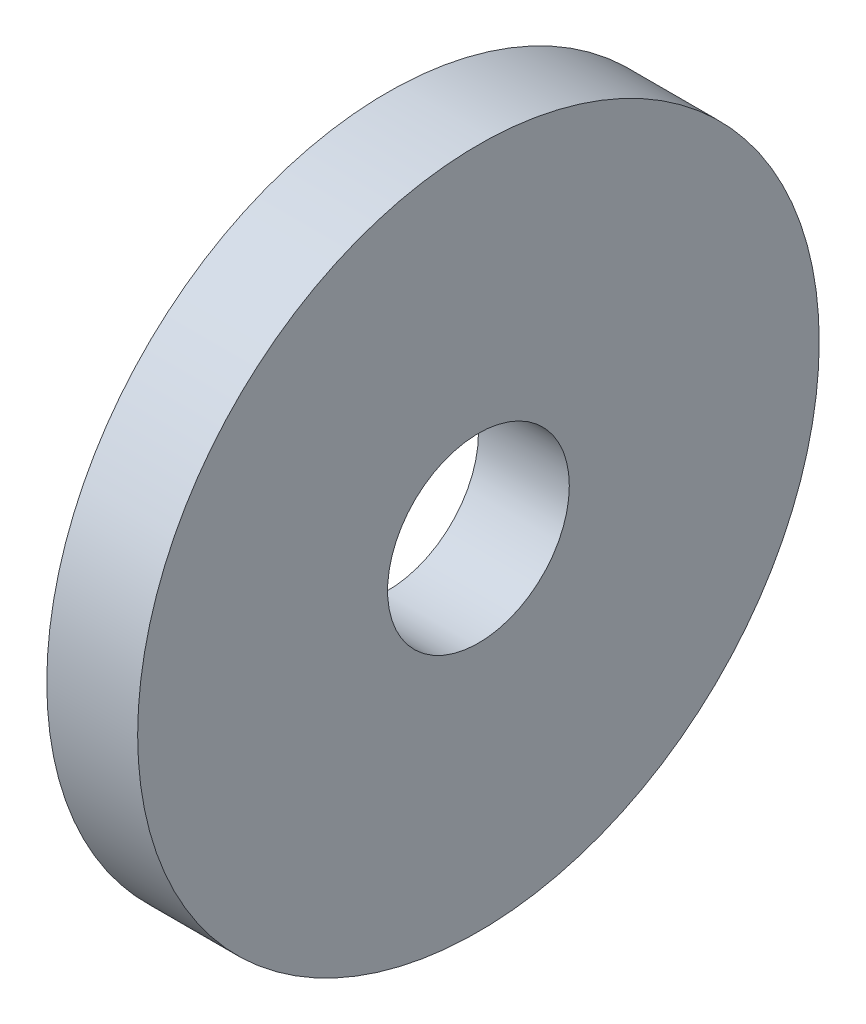
from build123d import *

# Parameters (mm, degrees)
SKETCH1_R           = 37.5
BOSS_EXTRUDE1_DEPTH = 10
SKETCH2_R           = 10
CUT_EXTRUDE1_DEPTH  = 11


with BuildPart() as part:
    # Sketch1 → Boss-Extrude1 (new body)
    with BuildSketch(Plane(origin=(0, 0, 0), x_dir=(0, 0, -1), z_dir=(1, 0, 0))):
        Circle(SKETCH1_R)
    extrude(amount=BOSS_EXTRUDE1_DEPTH)

    # Sketch2 → Cut-Extrude1 (cut, through all)
    with BuildSketch(Plane(origin=(10, 0, 0), x_dir=(0, 0, -1), z_dir=(1, 0, 0))):
        Circle(SKETCH2_R)
    extrude(amount=-CUT_EXTRUDE1_DEPTH, mode=Mode.SUBTRACT)


solid = part.part
